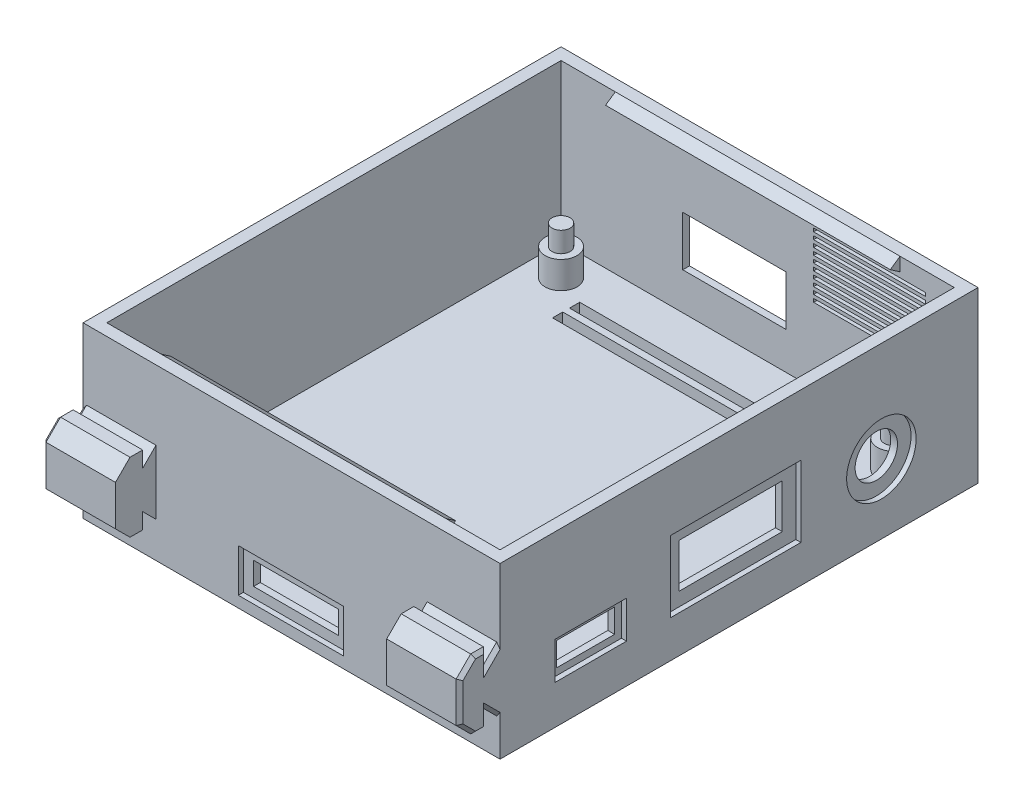
from build123d import *

# Parameters (mm, degrees)
SKETCH1_W                       = 61.5
SKETCH1_H                       = 70.5
SKETCH1_W_2                     = 58
SKETCH1_H_2                     = 67
BOSS_EXTRUDE1_DEPTH             = 25
SKETCH2_W                       = 61.5
SKETCH2_H                       = 70.5
BOSS_EXTRUDE5_DEPTH             = 1.75
SKETCH3_R                       = 2.35
BOSS_EXTRUDE2_DEPTH             = 4
SKETCH4_R                       = 1.325
BOSS_EXTRUDE3_DEPTH             = 3
CUT_EXTRUDE2_REACH              = 63.5
SKETCH5_R                       = 3.125
SKETCH5_W                       = 8.55
SKETCH5_H                       = 3.5
SKETCH5_W_2                     = 15.25
SKETCH5_H_2                     = 6.5
BOSS_EXTRUDE4_REACH             = 32.75
BOSS_EXTRUDE4_DIRECTION_2_REACH = 32.75
CUT_EXTRUDE3_START              = 4.89
SKETCH8_W                       = 40
SKETCH8_H                       = 5.97
CUT_EXTRUDE3_DEPTH              = 10.22
CUT_EXTRUDE4_REACH              = 78.47
SKETCH10_W                      = 15.2
SKETCH10_H                      = 7.35
SKETCH10_W_2                    = 16.5
SKETCH10_H_2                    = 0.5
CUT_EXTRUDE6_REACH              = 72.5
SKETCH13_W                      = 12.5
SKETCH13_H                      = 3.35
SKETCH14_R                      = 5.125
SKETCH14_W                      = 10.55
SKETCH14_H                      = 5.5
SKETCH14_W_2                    = 19.25
SKETCH14_H_2                    = 10.5
CUT_EXTRUDE7_DEPTH              = 0.75
SKETCH15_W                      = 18.2
SKETCH15_H                      = 10.35
CUT_EXTRUDE8_DEPTH              = 0.75
SKETCH17_W                      = 15.5
SKETCH17_H                      = 6.35
CUT_EXTRUDE9_DEPTH              = 0.75
BOSS_EXTRUDE6_DEPTH             = 21
BOSS_EXTRUDE6_DEPTH_BACK        = 21
SKETCH19_W                      = 40
SKETCH19_H                      = 1.5
CUT_EXTRUDE11_DEPTH             = 1.75
LPATTERN1_COUNT                 = 2
LPATTERN1_PITCH                 = 2.5
MIRROR1_COPY_1_SKETCH_W         = 40
MIRROR1_COPY_1_SKETCH_H         = 1.5
MIRROR1_COPY_1_DEPTH            = 1.75
CHAMFER1_SIZE                   = 0.5


with BuildPart() as part:
    # Sketch1 → Boss-Extrude1 (new body)
    with BuildSketch(Plane(origin=(0, 0, 0), x_dir=(1, 0, 0), z_dir=(0, 1, 0))):
        Rectangle(SKETCH1_W, SKETCH1_H)
        Rectangle(SKETCH1_W_2, SKETCH1_H_2, mode=Mode.SUBTRACT)
    extrude(amount=BOSS_EXTRUDE1_DEPTH)

    # Sketch2 → Boss-Extrude5 (add)
    with BuildSketch(Plane(origin=(0, 0, 0), x_dir=(1, 0, 0), z_dir=(0, 1, 0))):
        Rectangle(SKETCH2_W, SKETCH2_H)
    extrude(amount=BOSS_EXTRUDE5_DEPTH)

    # Sketch3 → Boss-Extrude2 (add)
    with BuildSketch(Plane(origin=(0, 1.75, 0), x_dir=(1, 0, 0), z_dir=(0, 1, 0))):
        with Locations((-24.5, 29)):
            Circle(SKETCH3_R)
        with Locations((24.5, 29)):
            Circle(SKETCH3_R)
        with Locations((24.5, -29)):
            Circle(SKETCH3_R)
        with Locations((-24.5, -29)):
            Circle(SKETCH3_R)
    extrude(amount=BOSS_EXTRUDE2_DEPTH)

    # Sketch4 → Boss-Extrude3 (add)
    with BuildSketch(Plane(origin=(0, 5.75, 0), x_dir=(1, 0, 0), z_dir=(0, 1, 0))):
        with Locations((-24.5, 29)):
            Circle(SKETCH4_R)
        with Locations((24.5, 29)):
            Circle(SKETCH4_R)
        with Locations((24.5, -29)):
            Circle(SKETCH4_R)
        with Locations((-24.5, -29)):
            Circle(SKETCH4_R)
    extrude(amount=BOSS_EXTRUDE3_DEPTH)

    # Sketch5 → Cut-Extrude2 (cut, up to next)
    with BuildSketch(Plane(origin=(30.75, 0, 0), x_dir=(0, 0, -1), z_dir=(1, 0, 0)), mode=Mode.PRIVATE) as cut_extrude2_sk1:
        with Locations((21, 10.24)):
            Circle(SKETCH5_R)
    cut_extrude2_tool1 = extrude(cut_extrude2_sk1.sketch, amount=-CUT_EXTRUDE2_REACH, mode=Mode.PRIVATE) & part.part
    add(cut_extrude2_tool1.solids().sort_by_distance((30.75, 10.24, -21))[0], mode=Mode.SUBTRACT)
    # Sketch5 → Cut-Extrude2 (cut, up to next)
    with BuildSketch(Plane(origin=(30.75, 0, 0), x_dir=(0, 0, -1), z_dir=(1, 0, 0)), mode=Mode.PRIVATE) as cut_extrude2_sk2:
        with Locations((-21.875, 8.5)):
            Rectangle(SKETCH5_W, SKETCH5_H)
    cut_extrude2_tool2 = extrude(cut_extrude2_sk2.sketch, amount=-CUT_EXTRUDE2_REACH, mode=Mode.PRIVATE) & part.part
    add(cut_extrude2_tool2.solids().sort_by_distance((30.75, 8.5, 21.875))[0], mode=Mode.SUBTRACT)
    # Sketch5 → Cut-Extrude2 (cut, up to next)
    with BuildSketch(Plane(origin=(30.75, 0, 0), x_dir=(0, 0, -1), z_dir=(1, 0, 0)), mode=Mode.PRIVATE) as cut_extrude2_sk3:
        with Locations((-0.5, 10.75)):
            Rectangle(SKETCH5_W_2, SKETCH5_H_2)
    cut_extrude2_tool3 = extrude(cut_extrude2_sk3.sketch, amount=-CUT_EXTRUDE2_REACH, mode=Mode.PRIVATE) & part.part
    add(cut_extrude2_tool3.solids().sort_by_distance((30.75, 10.75, 0.5))[0], mode=Mode.SUBTRACT)

    # Boss-Extrude4: up to this face of the body (flat: up to its plane)
    boss_extrude4_end = Plane(part.part.faces().sort_by_distance((30.75, 0.748014037, 0))[0])
    # Sketch7 → Boss-Extrude4 (add, up to the picked face)
    with BuildSketch(Plane(origin=(0, 0, 0), x_dir=(0, 0, -1), z_dir=(1, 0, 0)), mode=Mode.PRIVATE) as boss_extrude4_sk1:
        Polygon((-35.25, 14.73), (-35.25, 5.27), (-37.22, 7.24), (-37.22, 4.89), (-39.08, 4.89), (-41.22, 7.03), (-41.22, 12.97), (-39.08, 15.11), (-37.22, 15.11), (-37.22, 12.76), align=None)
    boss_extrude4_tool1 = split(extrude(boss_extrude4_sk1.sketch, amount=BOSS_EXTRUDE4_REACH, mode=Mode.PRIVATE), bisect_by=boss_extrude4_end, keep=Keep.BOTH, mode=Mode.PRIVATE)
    add(boss_extrude4_tool1.solids().sort_by_distance((0, 10, 38.216954))[0])

    # Boss-Extrude4 direction 2: up to this face of the body (flat: up to its plane)
    boss_extrude4_direction_2_end = Plane(part.part.faces().sort_by_distance((-30.75, 12.5, 0))[0])
    # Sketch7 → Boss-Extrude4 direction 2 (add, up to the picked face)
    with BuildSketch(Plane(origin=(0, 0, 0), x_dir=(0, 0, -1), z_dir=(1, 0, 0)), mode=Mode.PRIVATE) as boss_extrude4_direction_2_sk1:
        Polygon((-35.25, 14.73), (-35.25, 5.27), (-37.22, 7.24), (-37.22, 4.89), (-39.08, 4.89), (-41.22, 7.03), (-41.22, 12.97), (-39.08, 15.11), (-37.22, 15.11), (-37.22, 12.76), align=None)
    boss_extrude4_direction_2_tool1 = split(extrude(boss_extrude4_direction_2_sk1.sketch, amount=-BOSS_EXTRUDE4_DIRECTION_2_REACH, mode=Mode.PRIVATE), bisect_by=boss_extrude4_direction_2_end, keep=Keep.BOTH, mode=Mode.PRIVATE)
    add(boss_extrude4_direction_2_tool1.solids().sort_by_distance((0, 10, 38.216954))[0])

    # Sketch8 → Cut-Extrude3 (cut)
    with BuildSketch(Plane(origin=(0, 0, 0), x_dir=(1, 0, 0), z_dir=(0, 1, 0)).offset(CUT_EXTRUDE3_START)):
        with Locations((0, -38.235)):
            Rectangle(SKETCH8_W, SKETCH8_H)
    extrude(amount=CUT_EXTRUDE3_DEPTH, mode=Mode.SUBTRACT)

    # Sketch10 → Cut-Extrude4 (cut, up to next)
    with BuildSketch(Plane(origin=(0, 0, -35.25), x_dir=(-1, 0, 0), z_dir=(0, 0, -1)), mode=Mode.PRIVATE) as cut_extrude4_sk1:
        with Locations((3.45, 10.915)):
            Rectangle(SKETCH10_W, SKETCH10_H)
    cut_extrude4_tool1 = extrude(cut_extrude4_sk1.sketch, amount=-CUT_EXTRUDE4_REACH, mode=Mode.PRIVATE) & part.part
    add(cut_extrude4_tool1.solids().sort_by_distance((-3.45, 10.915, -35.25))[0], mode=Mode.SUBTRACT)
    # Sketch10 → Cut-Extrude4 (cut, up to next)
    with BuildSketch(Plane(origin=(0, 0, -35.25), x_dir=(-1, 0, 0), z_dir=(0, 0, -1)), mode=Mode.PRIVATE) as cut_extrude4_sk2:
        with Locations((-16.5, 21.99)):
            Rectangle(SKETCH10_W_2, SKETCH10_H_2)
    cut_extrude4_tool2 = extrude(cut_extrude4_sk2.sketch, amount=-CUT_EXTRUDE4_REACH, mode=Mode.PRIVATE) & part.part
    add(cut_extrude4_tool2.solids().sort_by_distance((16.5, 21.99, -35.25))[0], mode=Mode.SUBTRACT)
    # Sketch10 → Cut-Extrude4 (cut, up to next)
    with BuildSketch(Plane(origin=(0, 0, -35.25), x_dir=(-1, 0, 0), z_dir=(0, 0, -1)), mode=Mode.PRIVATE) as cut_extrude4_sk3:
        with Locations((-16.5, 20.99)):
            Rectangle(SKETCH10_W_2, SKETCH10_H_2)
    cut_extrude4_tool3 = extrude(cut_extrude4_sk3.sketch, amount=-CUT_EXTRUDE4_REACH, mode=Mode.PRIVATE) & part.part
    add(cut_extrude4_tool3.solids().sort_by_distance((16.5, 20.99, -35.25))[0], mode=Mode.SUBTRACT)
    # Sketch10 → Cut-Extrude4 (cut, up to next)
    with BuildSketch(Plane(origin=(0, 0, -35.25), x_dir=(-1, 0, 0), z_dir=(0, 0, -1)), mode=Mode.PRIVATE) as cut_extrude4_sk4:
        with Locations((-16.5, 19.99)):
            Rectangle(SKETCH10_W_2, SKETCH10_H_2)
    cut_extrude4_tool4 = extrude(cut_extrude4_sk4.sketch, amount=-CUT_EXTRUDE4_REACH, mode=Mode.PRIVATE) & part.part
    add(cut_extrude4_tool4.solids().sort_by_distance((16.5, 19.99, -35.25))[0], mode=Mode.SUBTRACT)
    # Sketch10 → Cut-Extrude4 (cut, up to next)
    with BuildSketch(Plane(origin=(0, 0, -35.25), x_dir=(-1, 0, 0), z_dir=(0, 0, -1)), mode=Mode.PRIVATE) as cut_extrude4_sk5:
        with Locations((-16.5, 18.99)):
            Rectangle(SKETCH10_W_2, SKETCH10_H_2)
    cut_extrude4_tool5 = extrude(cut_extrude4_sk5.sketch, amount=-CUT_EXTRUDE4_REACH, mode=Mode.PRIVATE) & part.part
    add(cut_extrude4_tool5.solids().sort_by_distance((16.5, 18.99, -35.25))[0], mode=Mode.SUBTRACT)
    # Sketch10 → Cut-Extrude4 (cut, up to next)
    with BuildSketch(Plane(origin=(0, 0, -35.25), x_dir=(-1, 0, 0), z_dir=(0, 0, -1)), mode=Mode.PRIVATE) as cut_extrude4_sk6:
        with Locations((-16.5, 17.99)):
            Rectangle(SKETCH10_W_2, SKETCH10_H_2)
    cut_extrude4_tool6 = extrude(cut_extrude4_sk6.sketch, amount=-CUT_EXTRUDE4_REACH, mode=Mode.PRIVATE) & part.part
    add(cut_extrude4_tool6.solids().sort_by_distance((16.5, 17.99, -35.25))[0], mode=Mode.SUBTRACT)
    # Sketch10 → Cut-Extrude4 (cut, up to next)
    with BuildSketch(Plane(origin=(0, 0, -35.25), x_dir=(-1, 0, 0), z_dir=(0, 0, -1)), mode=Mode.PRIVATE) as cut_extrude4_sk7:
        with Locations((-16.5, 16.99)):
            Rectangle(SKETCH10_W_2, SKETCH10_H_2)
    cut_extrude4_tool7 = extrude(cut_extrude4_sk7.sketch, amount=-CUT_EXTRUDE4_REACH, mode=Mode.PRIVATE) & part.part
    add(cut_extrude4_tool7.solids().sort_by_distance((16.5, 16.99, -35.25))[0], mode=Mode.SUBTRACT)
    # Sketch10 → Cut-Extrude4 (cut, up to next)
    with BuildSketch(Plane(origin=(0, 0, -35.25), x_dir=(-1, 0, 0), z_dir=(0, 0, -1)), mode=Mode.PRIVATE) as cut_extrude4_sk8:
        with Locations((-16.5, 15.99)):
            Rectangle(SKETCH10_W_2, SKETCH10_H_2)
    cut_extrude4_tool8 = extrude(cut_extrude4_sk8.sketch, amount=-CUT_EXTRUDE4_REACH, mode=Mode.PRIVATE) & part.part
    add(cut_extrude4_tool8.solids().sort_by_distance((16.5, 15.99, -35.25))[0], mode=Mode.SUBTRACT)
    # Sketch10 → Cut-Extrude4 (cut, up to next)
    with BuildSketch(Plane(origin=(0, 0, -35.25), x_dir=(-1, 0, 0), z_dir=(0, 0, -1)), mode=Mode.PRIVATE) as cut_extrude4_sk9:
        with Locations((-16.5, 14.99)):
            Rectangle(SKETCH10_W_2, SKETCH10_H_2)
    cut_extrude4_tool9 = extrude(cut_extrude4_sk9.sketch, amount=-CUT_EXTRUDE4_REACH, mode=Mode.PRIVATE) & part.part
    add(cut_extrude4_tool9.solids().sort_by_distance((16.5, 14.99, -35.25))[0], mode=Mode.SUBTRACT)
    # Sketch10 → Cut-Extrude4 (cut, up to next)
    with BuildSketch(Plane(origin=(0, 0, -35.25), x_dir=(-1, 0, 0), z_dir=(0, 0, -1)), mode=Mode.PRIVATE) as cut_extrude4_sk10:
        with Locations((-16.5, 13.99)):
            Rectangle(SKETCH10_W_2, SKETCH10_H_2)
    cut_extrude4_tool10 = extrude(cut_extrude4_sk10.sketch, amount=-CUT_EXTRUDE4_REACH, mode=Mode.PRIVATE) & part.part
    add(cut_extrude4_tool10.solids().sort_by_distance((16.5, 13.99, -35.25))[0], mode=Mode.SUBTRACT)
    # Sketch10 → Cut-Extrude4 (cut, up to next)
    with BuildSketch(Plane(origin=(0, 0, -35.25), x_dir=(-1, 0, 0), z_dir=(0, 0, -1)), mode=Mode.PRIVATE) as cut_extrude4_sk11:
        with Locations((-16.5, 12.99)):
            Rectangle(SKETCH10_W_2, SKETCH10_H_2)
    cut_extrude4_tool11 = extrude(cut_extrude4_sk11.sketch, amount=-CUT_EXTRUDE4_REACH, mode=Mode.PRIVATE) & part.part
    add(cut_extrude4_tool11.solids().sort_by_distance((16.5, 12.99, -35.25))[0], mode=Mode.SUBTRACT)

    # Sketch13 → Cut-Extrude6 (cut, up to next)
    with BuildSketch(Plane.XY.offset(35.25), mode=Mode.PRIVATE) as cut_extrude6_sk1:
        with Locations((-0.105, 4.815)):
            Rectangle(SKETCH13_W, SKETCH13_H)
    cut_extrude6_tool1 = extrude(cut_extrude6_sk1.sketch, amount=-CUT_EXTRUDE6_REACH, mode=Mode.PRIVATE) & part.part
    add(cut_extrude6_tool1.solids().sort_by_distance((-0.105, 4.815, 35.25))[0], mode=Mode.SUBTRACT)

    # Sketch14 → Cut-Extrude7 (cut)
    with BuildSketch(Plane(origin=(30.75, 0, 0), x_dir=(0, 0, -1), z_dir=(1, 0, 0))):
        with Locations((21, 10.24)):
            Circle(SKETCH14_R)
        with Locations((-21.875, 8.5)):
            Rectangle(SKETCH14_W, SKETCH14_H)
        with Locations((-0.5, 10.75)):
            Rectangle(SKETCH14_W_2, SKETCH14_H_2)
    extrude(amount=-CUT_EXTRUDE7_DEPTH, mode=Mode.SUBTRACT)

    # Sketch15 → Cut-Extrude8 (cut)
    with BuildSketch(Plane(origin=(0, 0, -35.25), x_dir=(-1, 0, 0), z_dir=(0, 0, -1))):
        with Locations((3.45, 10.915)):
            Rectangle(SKETCH15_W, SKETCH15_H)
    extrude(amount=-CUT_EXTRUDE8_DEPTH, mode=Mode.SUBTRACT)

    # Sketch17 → Cut-Extrude9 (cut)
    with BuildSketch(Plane.XY.offset(35.25)):
        with Locations((-0.105, 4.815)):
            Rectangle(SKETCH17_W, SKETCH17_H)
    extrude(amount=-CUT_EXTRUDE9_DEPTH, mode=Mode.SUBTRACT)

    # Sketch18 → Boss-Extrude6 (add, two sides)
    with BuildSketch(Plane(origin=(0, 0, 0), x_dir=(0, 0, -1), z_dir=(1, 0, 0))) as boss_extrude6_sk:
        Polygon((-33.5, 25), (-32.063859338, 24), (-33.5, 23), align=None)
        Polygon((33.5, 25), (33.5, 23), (32.063859338, 24), align=None)
    extrude(amount=BOSS_EXTRUDE6_DEPTH)
    extrude(boss_extrude6_sk.sketch, amount=-BOSS_EXTRUDE6_DEPTH_BACK)

    # Sketch19 → Cut-Extrude11 (cut)
    with BuildSketch(Plane(origin=(0, 0, 0), x_dir=(1, 0, 0), z_dir=(0, 1, 0))):
        with Locations((0, 26.5)):
            Rectangle(SKETCH19_W, SKETCH19_H)
    cut_extrude11 = extrude(amount=CUT_EXTRUDE11_DEPTH, mode=Mode.SUBTRACT)

    # LPattern1: Cut-Extrude11 ×2
    with Locations(*[(0, 0, i * LPATTERN1_PITCH) for i in range(1, LPATTERN1_COUNT)]):
        add(cut_extrude11, mode=Mode.SUBTRACT)

    # Mirror1: Cut-Extrude11 across plane
    add(cut_extrude11.mirror(Plane.XY), mode=Mode.SUBTRACT)

    # Mirror1 copy 1 sketch → Mirror1 copy 1 (cut)
    with BuildSketch(Plane(origin=(0, 0, -2.5), x_dir=(1, 0, 0), z_dir=(0, 1, 0))):
        with Locations((0, -26.5)):
            Rectangle(MIRROR1_COPY_1_SKETCH_W, MIRROR1_COPY_1_SKETCH_H)
    extrude(amount=MIRROR1_COPY_1_DEPTH, mode=Mode.SUBTRACT)

    # Chamfer1
    chamfer1_edges = [part.edges().sort_by_distance(p)[0] for p in [
        (30.75, 6.255, 36.235),
        (30.75, 6.065, 37.22),
        (30.75, 4.89, 38.15),
        (30.75, 5.96, 40.15),
        (30.75, 10, 41.22),
        (30.75, 14.04, 40.15),
        (30.75, 15.11, 38.15),
        (30.75, 13.935, 37.22),
        (30.75, 13.745, 36.235),
        (-30.75, 13.745, 36.235),
        (-30.75, 6.255, 36.235),
        (-30.75, 6.065, 37.22),
        (-30.75, 4.89, 38.15),
        (-30.75, 5.96, 40.15),
        (-30.75, 10, 41.22),
        (-30.75, 14.04, 40.15),
        (-30.75, 15.11, 38.15),
        (-30.75, 13.935, 37.22),
    ]]
    chamfer(chamfer1_edges, length=CHAMFER1_SIZE)


solid = part.part
